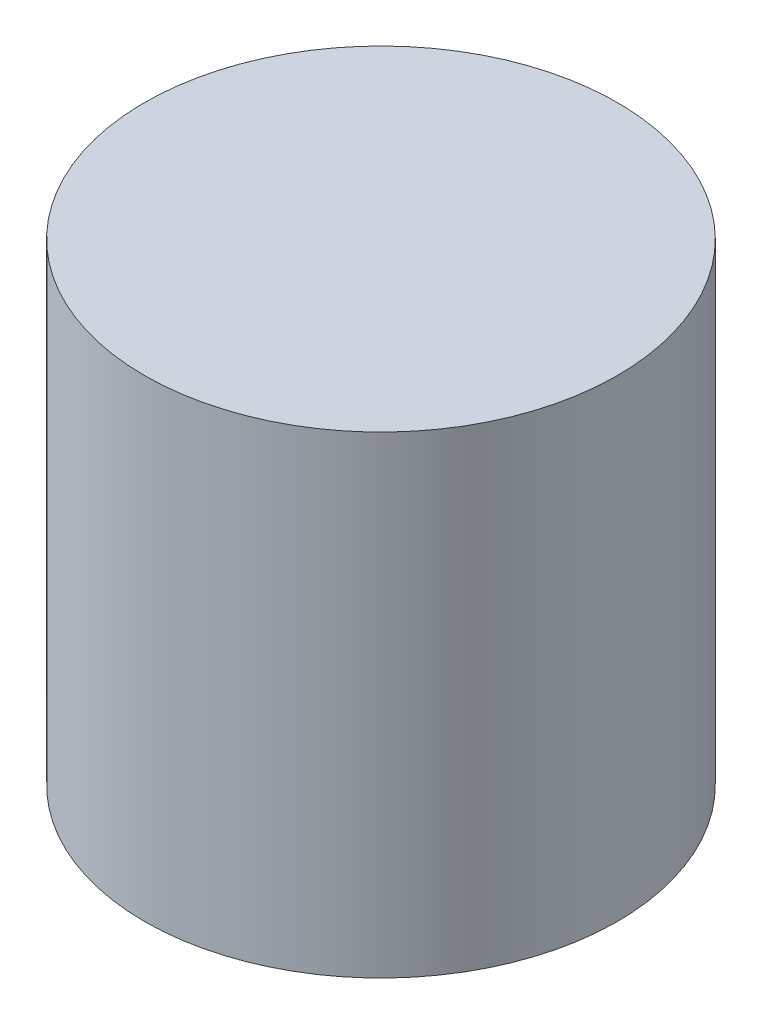
from build123d import *

# Parameters (mm, degrees)
SKETCH1_R           = 6.35
BOSS_EXTRUDE1_DEPTH = 12.7


with BuildPart() as part:
    # Sketch1 → Boss-Extrude1 (new body)
    with BuildSketch(Plane(origin=(0, 0, 0), x_dir=(1, 0, 0), z_dir=(0, 1, 0))):
        Circle(SKETCH1_R)
    extrude(amount=BOSS_EXTRUDE1_DEPTH)


solid = part.part
